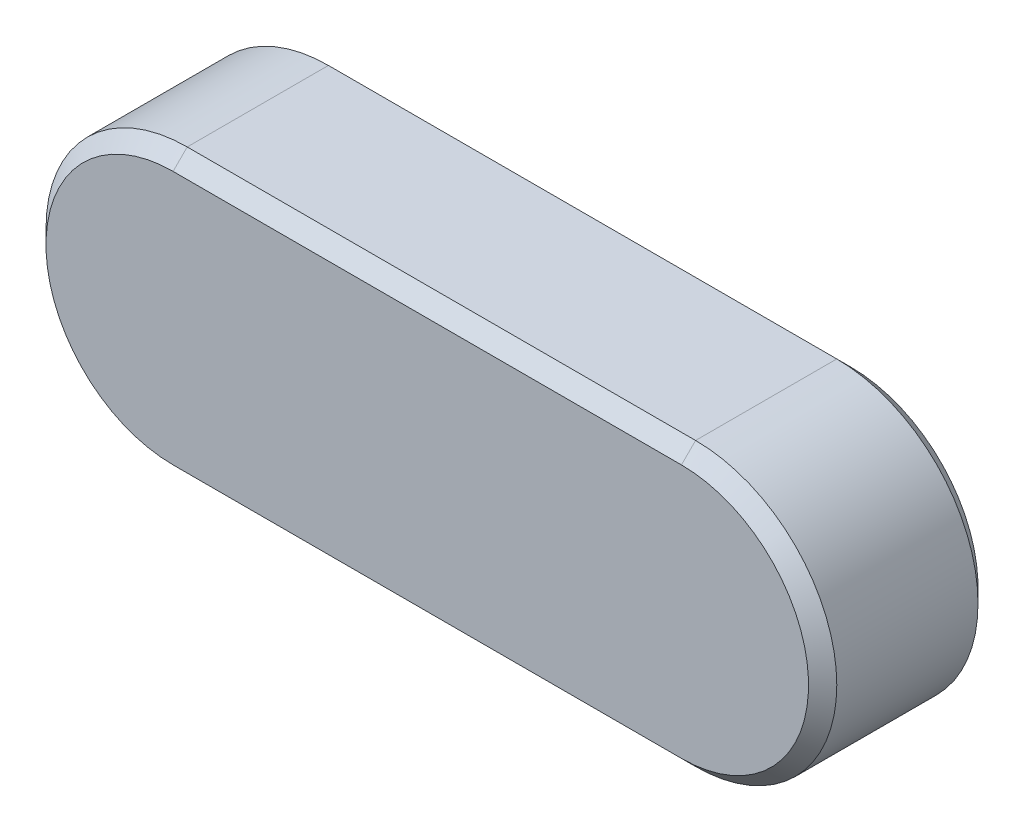
from build123d import *

# Parameters (mm, degrees)
EXTRUDE1_DEPTH = 3
CHAMFER1_SIZE  = 0.25


with BuildPart() as part:
    # Sketch1 → Extrude1 (new body)
    with BuildSketch(Plane.XY):
        with BuildLine():
            Line((0, 2.5), (-9, 2.5))
            ThreePointArc((-9, 2.5), (-11.5, 0), (-9, -2.5))
            Line((-9, -2.5), (0, -2.5))
            ThreePointArc((0, -2.5), (2.5, 0), (0, 2.5))
        make_face()
    extrude(amount=EXTRUDE1_DEPTH)

    # Chamfer1
    chamfer1_edges = [part.edges().sort_by_distance(p)[0] for p in [
        (-11.5, 0, 3),
        (-4.5, -2.5, 3),
        (2.5, 0, 3),
        (-4.5, -2.5, 0),
        (-11.5, 0, 0),
        (-4.5, 2.5, 0),
        (2.5, 0, 0),
        (-4.5, 2.5, 3),
    ]]
    chamfer(chamfer1_edges, length=CHAMFER1_SIZE)


solid = part.part
